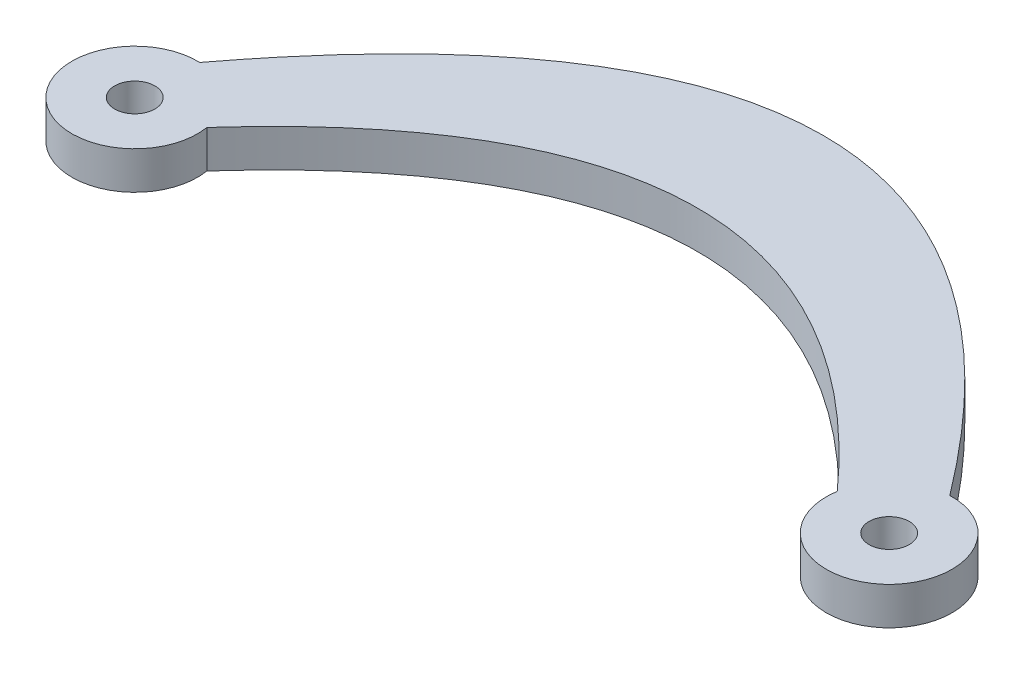
from build123d import *

# Parameters (mm, degrees)
SKETCH1_R           = 1.6
BOSS_EXTRUDE1_DEPTH = 3


with BuildPart() as part:
    # Sketch1 → Boss-Extrude1 (new body)
    with BuildSketch(Plane(origin=(0, 0, 0), x_dir=(1, 0, 0), z_dir=(0, 1, 0))):
        with BuildLine():
            ThreePointArc((-59.826654002, 10.230460246), (-63.30397667, 1.480635346), (-55.065238323, 6.038529506))
            add(Edge.make_bspline(
                [(-55.065238323, 6.038529506), (-46.710158882, 15.346176502), (-30, 24.653823498), (-13.289841118, 15.346176502), (-4.934761677, 6.038529506)],
                knots=[0.082246028, 0.082246028, 0.082246028, 0.082246028, 0.5, 0.917753972, 0.917753972, 0.917753972, 0.917753972], degree=3))
            ThreePointArc((-4.934761677, 6.038529506), (3.30397667, 1.480635346), (-0.173345998, 10.230460246))
            add(Edge.make_bspline(
                [(-59.826654002, 10.230460246), (-49.884436001, 23.410153415), (-30, 36.589846585), (-10.115563999, 23.410153415), (-0.173345998, 10.230460246)],
                knots=[0.0028891, 0.0028891, 0.0028891, 0.0028891, 0.5, 0.9971109, 0.9971109, 0.9971109, 0.9971109], degree=3))
        make_face()
        with Locations((-60, 5.233466033)):
            Circle(SKETCH1_R, mode=Mode.SUBTRACT)
        with Locations((0, 5.233466033)):
            Circle(SKETCH1_R, mode=Mode.SUBTRACT)
    extrude(amount=BOSS_EXTRUDE1_DEPTH)


solid = part.part
